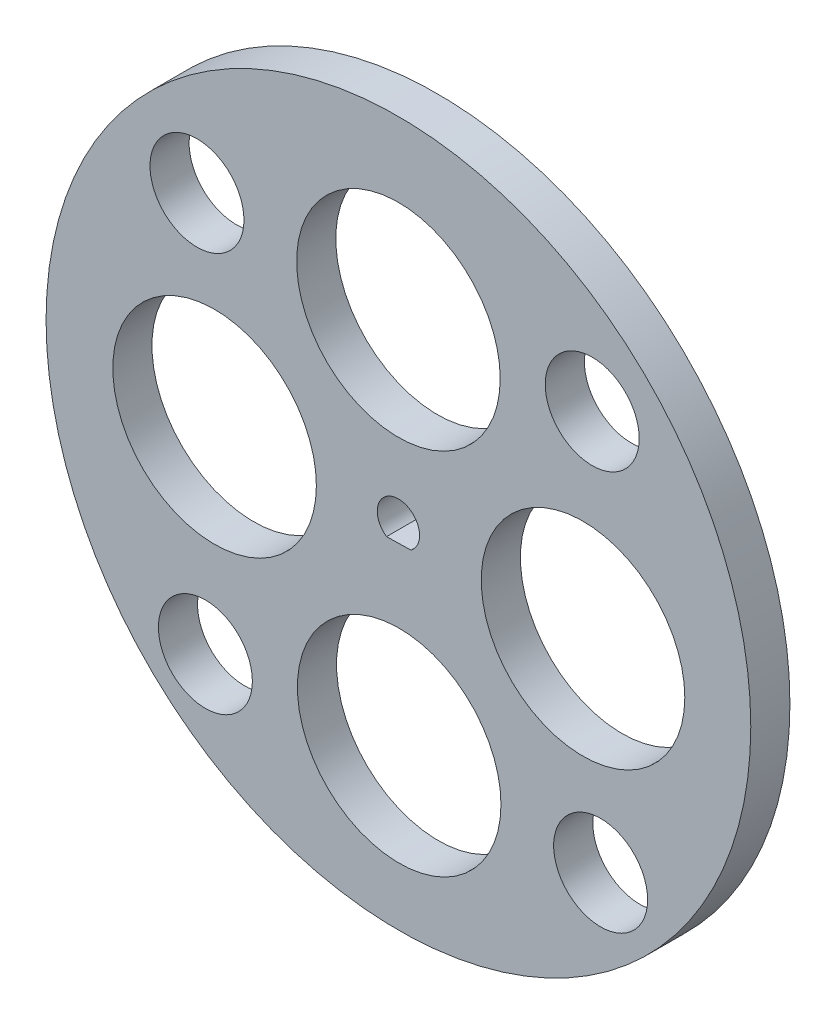
from build123d import *

# Parameters (mm, degrees)
ESQUISSE1_R        = 45
ESQUISSE1_R_2      = 13
ESQUISSE1_R_3      = 6
BOSS_EXTRU_1_DEPTH = 5


with BuildPart() as part:
    # Esquisse1 → Boss.-Extru.1 (new body)
    with BuildSketch(Plane.XY):
        with Locations((-0.047735681, 1.026587535)):
            Circle(ESQUISSE1_R)
        with Locations((-0.047735681, 23.526587535)):
            Circle(ESQUISSE1_R_2, mode=Mode.SUBTRACT)
        with Locations((23.526587535, 0.047735681)):
            Circle(ESQUISSE1_R_2, mode=Mode.SUBTRACT)
        with Locations((0.047735681, -23.526587535)):
            Circle(ESQUISSE1_R_2, mode=Mode.SUBTRACT)
        with Locations((-23.526587535, -0.047735681)):
            Circle(ESQUISSE1_R_2, mode=Mode.SUBTRACT)
        with Locations((24.70100166, 25.775324877)):
            Circle(ESQUISSE1_R_3, mode=Mode.SUBTRACT)
        with Locations((25.775324877, -24.70100166)):
            Circle(ESQUISSE1_R_3, mode=Mode.SUBTRACT)
        with Locations((-24.70100166, -25.775324877)):
            Circle(ESQUISSE1_R_3, mode=Mode.SUBTRACT)
        with Locations((-25.775324877, 24.70100166)):
            Circle(ESQUISSE1_R_3, mode=Mode.SUBTRACT)
        with BuildLine():
            Line((-1.565957185, -1.206124597), (1.563345795, -1.140072677))
            ThreePointArc((1.563345795, -1.140072677), (-0.104713375, 3.725986273), (-1.565957185, -1.206124597))
        make_face(mode=Mode.SUBTRACT)
    extrude(amount=BOSS_EXTRU_1_DEPTH)


solid = part.part
